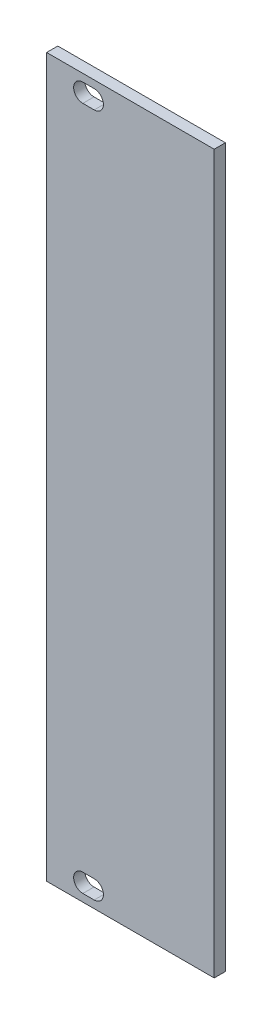
from build123d import *

# Parameters (mm, degrees)
SKETCH1_W           = 30
SKETCH1_H           = 128.5
BOSS_EXTRUDE1_DEPTH = 2


with BuildPart() as part:
    # Sketch1 → Boss-Extrude1 (new body)
    with BuildSketch(Plane.XY):
        Rectangle(SKETCH1_W, SKETCH1_H)
        with BuildLine():
            Line((-8.516, -59.6), (-6.484, -59.6))
            ThreePointArc((-6.484, -59.6), (-4.834, -61.25), (-6.484, -62.9))
            Line((-6.484, -62.9), (-8.516, -62.9))
            ThreePointArc((-8.516, -62.9), (-10.166, -61.25), (-8.516, -59.6))
        make_face(mode=Mode.SUBTRACT)
        with BuildLine():
            Line((-8.516, 62.9), (-6.484, 62.9))
            ThreePointArc((-6.484, 62.9), (-4.834, 61.25), (-6.484, 59.6))
            Line((-6.484, 59.6), (-8.516, 59.6))
            ThreePointArc((-8.516, 59.6), (-10.166, 61.25), (-8.516, 62.9))
        make_face(mode=Mode.SUBTRACT)
    extrude(amount=BOSS_EXTRUDE1_DEPTH)


solid = part.part
